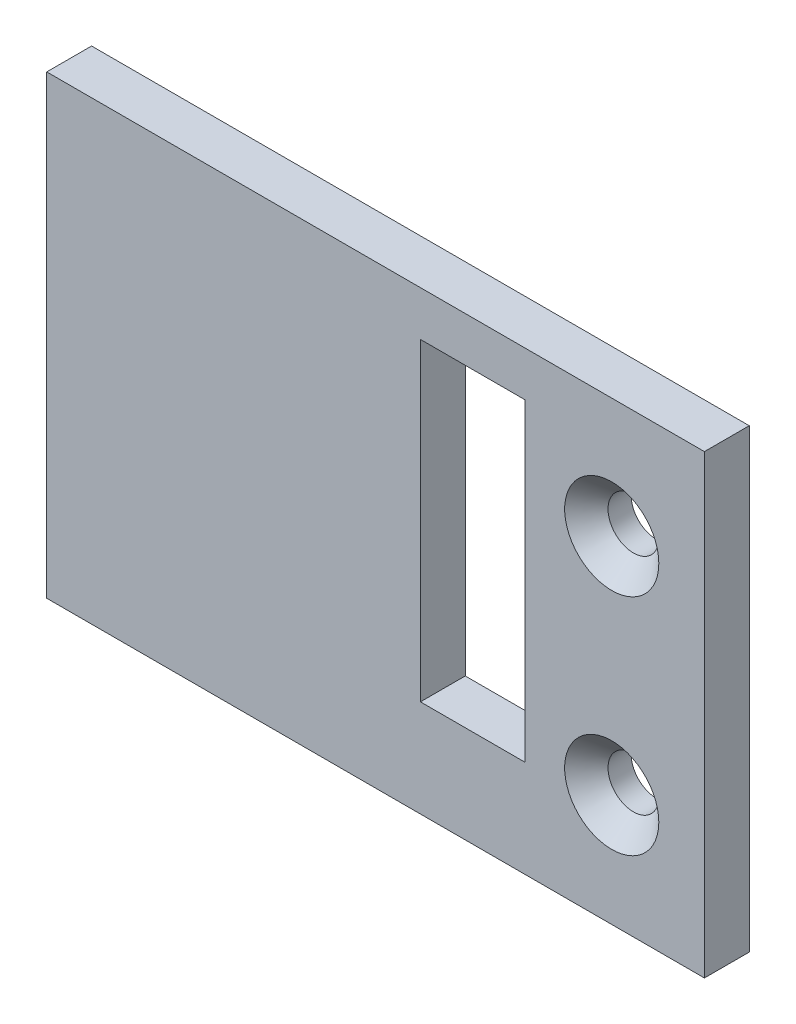
from build123d import *

# Parameters (mm, degrees)
SKETCH1_W                                      = 12
SKETCH1_H                                      = 30.5
SKETCH1_R                                      = 1.383995923
SKETCH1_R_2                                    = 1.420525084
BOSS_EXTRUDE1_DEPTH                            = 3
CSK_FOR_M3_FLAT_HEAD_MACHINE_SCREW1_AT_2_COUNT = 2
CSK_FOR_M3_FLAT_HEAD_MACHINE_SCREW1_AT_2_PITCH = 15


with BuildPart() as part:
    # Sketch1 → Boss-Extrude1 (new body)
    with BuildSketch(Plane.XY):
        Polygon((-6, 12.25), (-6, 15.25), (-38, 15.25), (-38, -15.25), (-6, -15.25), (-6, -8.75), (-13, -8.75), (-13, 12.25), align=None)
        Rectangle(SKETCH1_W, SKETCH1_H)
        with Locations((-0.2, 7.25)):
            Circle(SKETCH1_R, mode=Mode.SUBTRACT)
        with Locations((-0.2, -7.75)):
            Circle(SKETCH1_R_2, mode=Mode.SUBTRACT)
    extrude(amount=BOSS_EXTRUDE1_DEPTH)

    # Sketch4 → CSK for M3 Flat Head Machine Screw1 (revolve, cut)
    with BuildSketch(Plane(origin=(-0.2, 7.25, 3), x_dir=(0, -1, 0), z_dir=(1, 0, 0))):
        Polygon((0, 0), (0, 3), (1.7, 3), (1.7, 1.45), (3.15, 0), align=None)
    csk_for_m3_flat_head_machine_screw1 = revolve(axis=Axis((-0.2, 7.25, 9.35), (0, 0, -1)), mode=Mode.SUBTRACT)

    # CSK for M3 Flat Head Machine Screw1 at 2: CSK for M3 Flat Head Machine Screw1 ×2
    with Locations(*[(0, -i * CSK_FOR_M3_FLAT_HEAD_MACHINE_SCREW1_AT_2_PITCH, 0) for i in range(1, CSK_FOR_M3_FLAT_HEAD_MACHINE_SCREW1_AT_2_COUNT)]):
        add(csk_for_m3_flat_head_machine_screw1, mode=Mode.SUBTRACT)


solid = part.part
